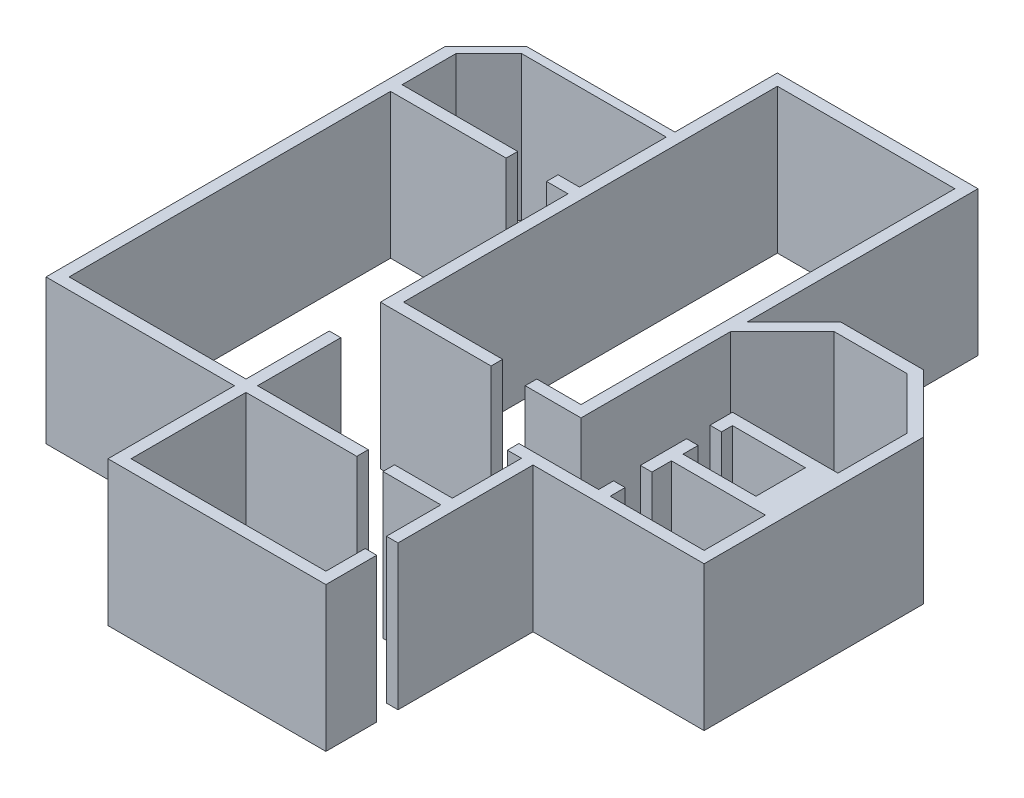
from build123d import *

# Parameters (mm, degrees)
BOSS_EXTRUDE1_DEPTH = 2500


with BuildPart() as part:
    # Sketch1 → Boss-Extrude1 (new body)
    with BuildSketch(Plane(origin=(0, 0, 0), x_dir=(1, 0, 0), z_dir=(0, 1, 0))):
        Polygon((959.373842867, 1394.56463349), (959.373842867, 2590), (66.049525486, 3483.324317381), (-1197.301839752, 3483.324317381), (-2090.626157133, 2590), (-2090.626157133, 0), (-3055.667562724, 0), (-3055.667562724, 200), (-2290.626157133, 200), (-2290.626157133, 6667.596809264), (-5360.626157133, 6667.596809264), (-5360.626157133, 200), (-3647.025316722, 200), (-3647.025316722, 0), (-5560.626157133, 0), (-5560.626157133, 3244.709781271), (-5931.668920541, 3244.709781271), (-5931.668920541, 3444.709781271), (-5560.626157133, 3444.709781271), (-5560.626157133, 4944.709781271), (-8060.626157133, 4944.709781271), (-8630.626157133, 4374.709781271), (-8630.626157133, 3444.709781271), (-6630.626157133, 3444.709781271), (-6630.626157133, 3244.709781271), (-8630.626157133, 3244.709781271), (-8630.626157133, -2315.290218729), (-5570.626157133, -2315.290218729), (-5570.626157133, -875.290218729), (-5370.626157133, -875.290218729), (-5370.626157133, -2315.290218729), (-3454.716376336, -2315.290218729), (-3454.716376336, -2515.290218729), (-5370.626157133, -2515.290218729), (-5370.626157133, -4503.431868327), (-2000.626157133, -4503.431868327), (-2000.626157133, -3823.682857884), (-1800.626157133, -3823.682857884), (-1800.626157133, -4703.431868327), (-5570.626157133, -4703.431868327), (-5570.626157133, -2515.290218729), (-8830.626157133, -2515.290218729), (-8830.626157133, 4386.841815627), (-8122.758191489, 5094.709781271), (-5560.626157133, 5094.709781271), (-5560.626157133, 6867.596809264), (-2090.626157133, 6867.596809264), (-2090.626157133, 2872.842712475), (-1280.144552227, 3683.324317381), (148.89223796, 3683.324317381), (1159.373842867, 2672.842712475), (1159.373842867, -1120.323035623), (-1800.626157133, -1120.323035623), (-1800.626157133, -3455.874270038), (-2000.626157133, -3455.874270038), (-2000.626157133, -2515.290218729), (-3001.468171969, -2515.290218729), (-3001.468171969, -2315.290218729), (-2000.626157133, -2315.290218729), (-2000.626157133, -1120.323035623), (-2244.585344705, -1120.323035623), (-2244.585344705, -920.323035623), (-865.76253991, -920.323035623), (-865.76253991, -661.352497341), (-665.76253991, -661.352497341), (-665.76253991, -920.323035623), (959.373842867, -920.323035623), (959.373842867, 139.138374563), (-665.76253991, 139.138374563), (-665.76253991, -198.081222703), (-865.76253991, -198.081222703), (-865.76253991, 601.688140889), (-665.76253991, 601.688140889), (-665.76253991, 339.138374563), (596.112266743, 339.138374563), (596.112266743, 1194.56463349), (-665.76253991, 1194.56463349), (-665.76253991, 1006.025679399), (-865.76253991, 1006.025679399), (-865.76253991, 1394.56463349), align=None)
    extrude(amount=BOSS_EXTRUDE1_DEPTH)


solid = part.part
